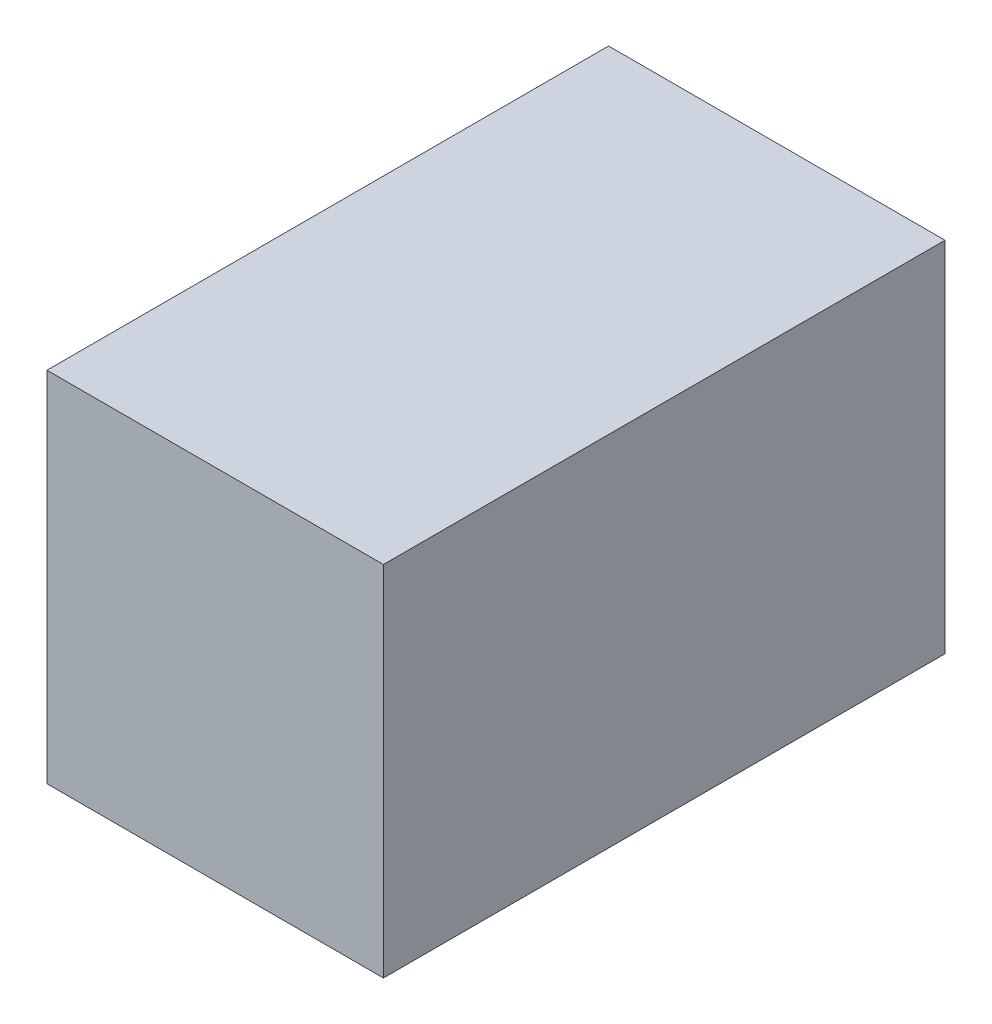
from build123d import *

# Parameters (mm, degrees)
SKETCH4_W           = 31.05
SKETCH4_H           = 18.35
BOSS_EXTRUDE1_DEPTH = 19
SHELL1_T            = 2
SKETCH5_W           = 12
SKETCH5_H           = 18.35
CUT_EXTRUDE1_DEPTH  = 2


with BuildPart() as part:
    # Sketch4 → Boss-Extrude1 (new body)
    with BuildSketch(Plane(origin=(0, 0, 0), x_dir=(0, 0, -1), z_dir=(1, 0, 0))):
        Rectangle(SKETCH4_W, SKETCH4_H)
    extrude(amount=BOSS_EXTRUDE1_DEPTH)

    # Shell1
    shell1_openings = [part.faces().sort_by_distance(p)[0] for p in [
        (0, 0, 0),
    ]]
    offset(amount=SHELL1_T, openings=shell1_openings, kind=Kind.INTERSECTION)

    # Sketch5 → Cut-Extrude1 (cut)
    with BuildSketch(Plane(origin=(0, 0, -17.525), x_dir=(-1, 0, 0), z_dir=(0, 0, -1))):
        with Locations((-6, 0)):
            Rectangle(SKETCH5_W, SKETCH5_H)
    extrude(amount=-CUT_EXTRUDE1_DEPTH, mode=Mode.SUBTRACT)


solid = part.part
